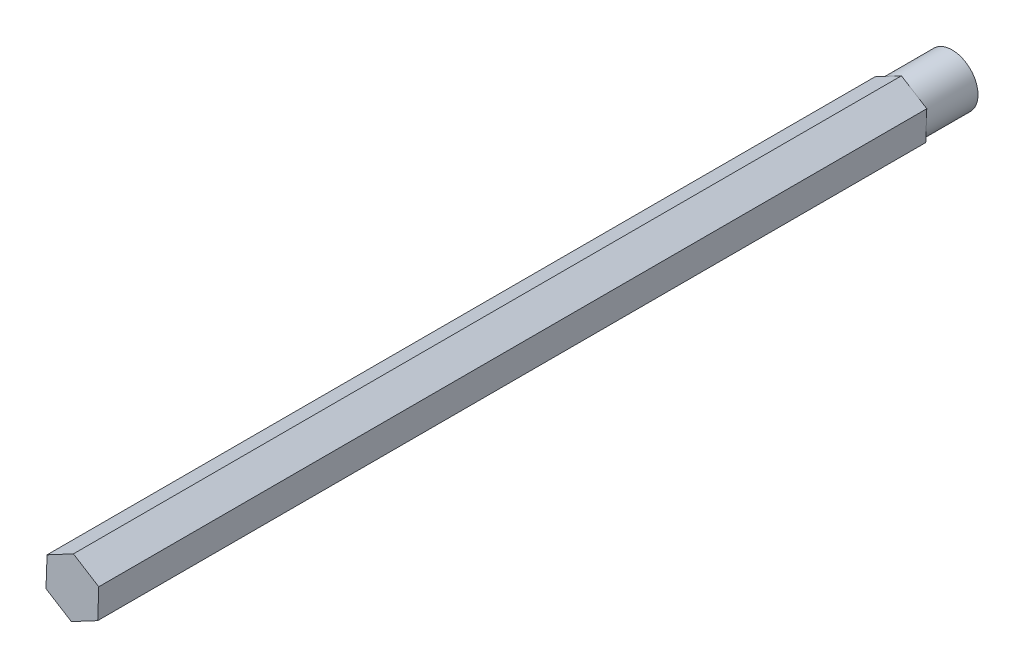
from build123d import *

# Parameters (mm, degrees)
BOSS_EXTRUDE1_DEPTH = 203.2
SKETCH2_R           = 6.35
BOSS_EXTRUDE2_DEPTH = 12.7


with BuildPart() as part:
    # Sketch1 → Boss-Extrude1 (new body)
    with BuildSketch(Plane.XY):
        Polygon((6.217819023, -3.88613689), (6.474402781, 3.441720786), (0.256583757, 7.327857675), (-6.217819023, 3.88613689), (-6.474402781, -3.441720786), (-0.256583757, -7.327857675), align=None)
    extrude(amount=BOSS_EXTRUDE1_DEPTH)

    # Sketch2 → Boss-Extrude2 (add)
    with BuildSketch(Plane(origin=(0, 0, 0), x_dir=(-1, 0, 0), z_dir=(0, 0, -1))):
        Circle(SKETCH2_R)
    extrude(amount=BOSS_EXTRUDE2_DEPTH)


solid = part.part
